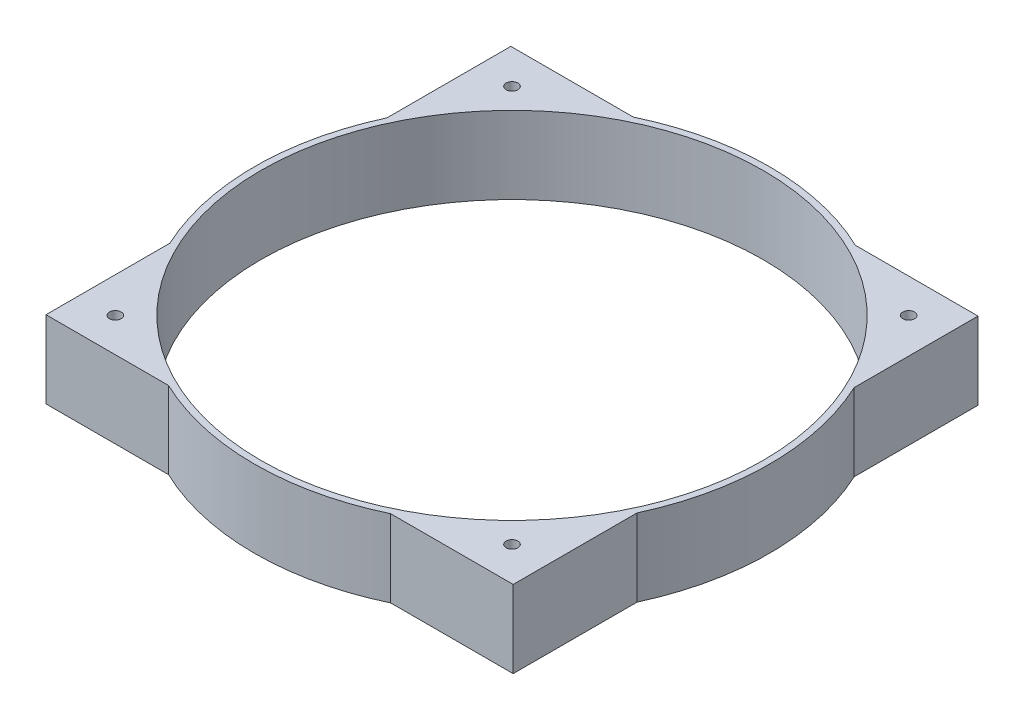
from build123d import *

# Parameters (mm, degrees)
SKETCH1_R           = 100
SKETCH1_W           = 181.371629942
SKETCH1_H           = 180.45561161
BOSS_EXTRUDE1_DEPTH = 30
SKETCH2_R           = 2.28
CUT_EXTRUDE1_DEPTH  = 31
SKETCH3_R           = 97.5
CUT_EXTRUDE2_DEPTH  = 30


with BuildPart() as part:
    # Sketch1 → Boss-Extrude1 (new body)
    with BuildSketch(Plane(origin=(0, 0, 0), x_dir=(1, 0, 0), z_dir=(0, 1, 0))):
        Circle(SKETCH1_R)
        Rectangle(SKETCH1_W, SKETCH1_H)
    extrude(amount=BOSS_EXTRUDE1_DEPTH)

    # Sketch2 → Cut-Extrude1 (cut, through all)
    with BuildSketch(Plane(origin=(0, 30, 0), x_dir=(1, 0, 0), z_dir=(0, 1, 0))):
        with Locations((-77, 77)):
            Circle(SKETCH2_R)
        with Locations((77, 77)):
            Circle(SKETCH2_R)
        with Locations((-77, -77)):
            Circle(SKETCH2_R)
        with Locations((77, -77)):
            Circle(SKETCH2_R)
    extrude(amount=-CUT_EXTRUDE1_DEPTH, mode=Mode.SUBTRACT)

    # Sketch3 → Cut-Extrude2 (cut)
    with BuildSketch(Plane(origin=(0, 0, 0), x_dir=(-1, 0, 0), z_dir=(0, -1, 0))):
        Circle(SKETCH3_R)
    extrude(amount=-CUT_EXTRUDE2_DEPTH, mode=Mode.SUBTRACT)


solid = part.part
